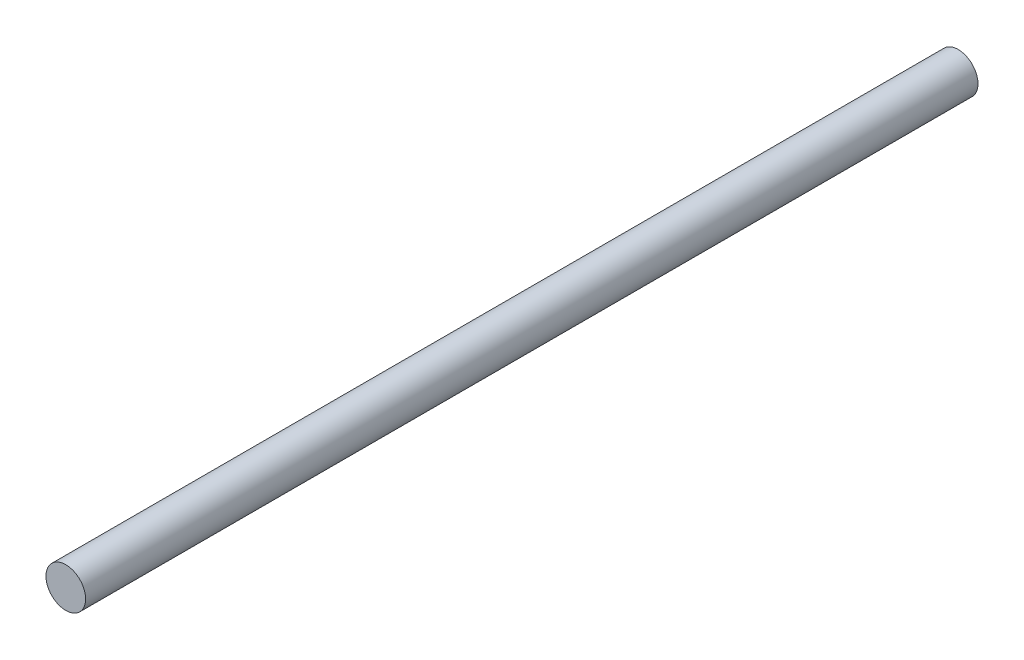
from build123d import *

# Parameters (mm, degrees)
SKETCH_1_R      = 4
EXTRUDE_1_DEPTH = 180


with BuildPart() as part:
    # 草图1 → 凸台-拉伸1 (new body)
    with BuildSketch(Plane.XY):
        Circle(SKETCH_1_R)
    extrude(amount=EXTRUDE_1_DEPTH)


solid = part.part
